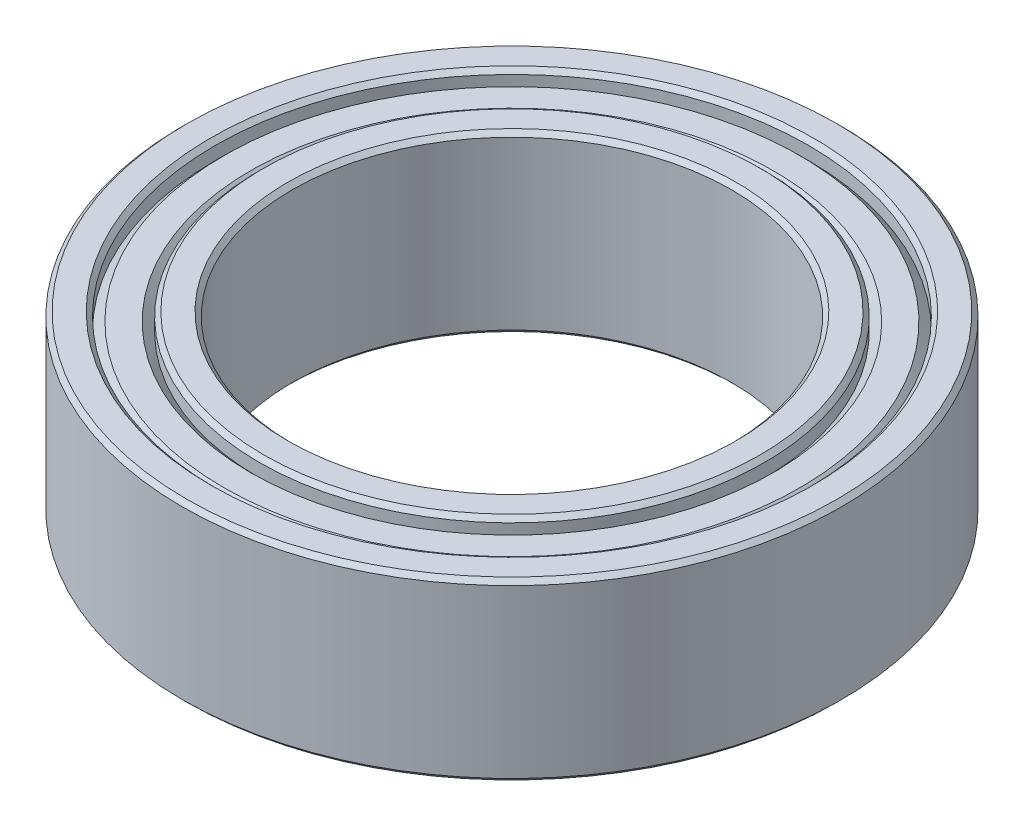
from build123d import *

# Parameters (mm, degrees)
SKETCH1_W     = 2.5
SKETCH1_H     = 4
CHAMFER1_SIZE = 0.1


with BuildPart() as part:
    # Sketch1 → Revolve1 (revolve)
    with BuildSketch(Plane(origin=(0, 0, 0), x_dir=(0, 0, -1), z_dir=(1, 0, 0))):
        with Locations((6.25, 0)):
            Rectangle(SKETCH1_W, SKETCH1_H)
    revolve(axis=Axis((0, 2, 0), (0, -1, 0)))

    # Sketch3 → Cut-Revolve2 (revolve, cut)
    with BuildSketch(Plane(origin=(0, 0, 0), x_dir=(0, 0, -1), z_dir=(1, 0, 0))):
        Polygon((6.55, 1.8), (6.75, 1.6), (6.75, 2), (5.75, 2), (5.75, 1.6), (5.95, 1.8), align=None)
    cut_revolve2 = revolve(axis=Axis((0, 2, 0), (0, -1, 0)), mode=Mode.SUBTRACT)

    # Mirror1: Cut-Revolve2 across plane
    add(cut_revolve2.mirror(Plane.ZX), mode=Mode.SUBTRACT)

    # Chamfer1
    chamfer1_edges = [part.edges().sort_by_distance(p)[0] for p in [
        (0, 2, 6.75),
        (0, 2, 5.75),
        (0, -2, 6.75),
        (0, -2, 5.75),
        (0, 2, 7.5),
        (0, -2, 7.5),
        (0, -2, 5),
        (0, 2, 5),
    ]]
    chamfer(chamfer1_edges, length=CHAMFER1_SIZE)


solid = part.part
